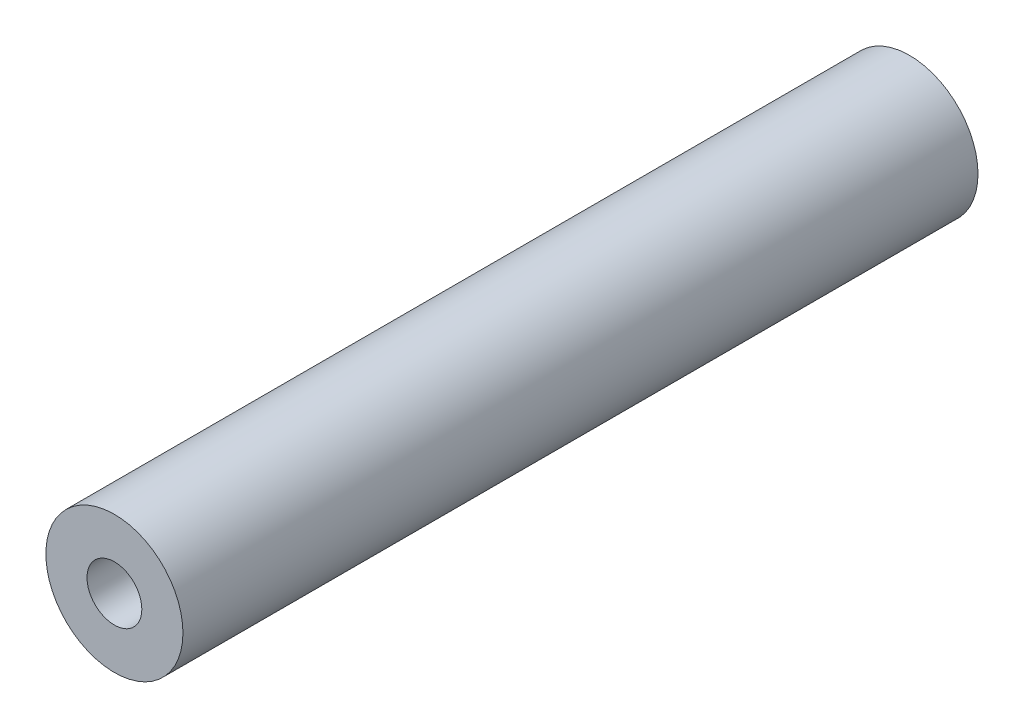
from build123d import *

# Parameters (mm, degrees)
SKETCH1_R           = 5
SKETCH1_R_2         = 2
BOSS_EXTRUDE1_DEPTH = 58


with BuildPart() as part:
    # Sketch1 → Boss-Extrude1 (new body)
    with BuildSketch(Plane.XY):
        with Locations((4.606634439, -4.471145191)):
            Circle(SKETCH1_R)
        with Locations((4.606634439, -4.471145191)):
            Circle(SKETCH1_R_2, mode=Mode.SUBTRACT)
    extrude(amount=BOSS_EXTRUDE1_DEPTH)


solid = part.part
